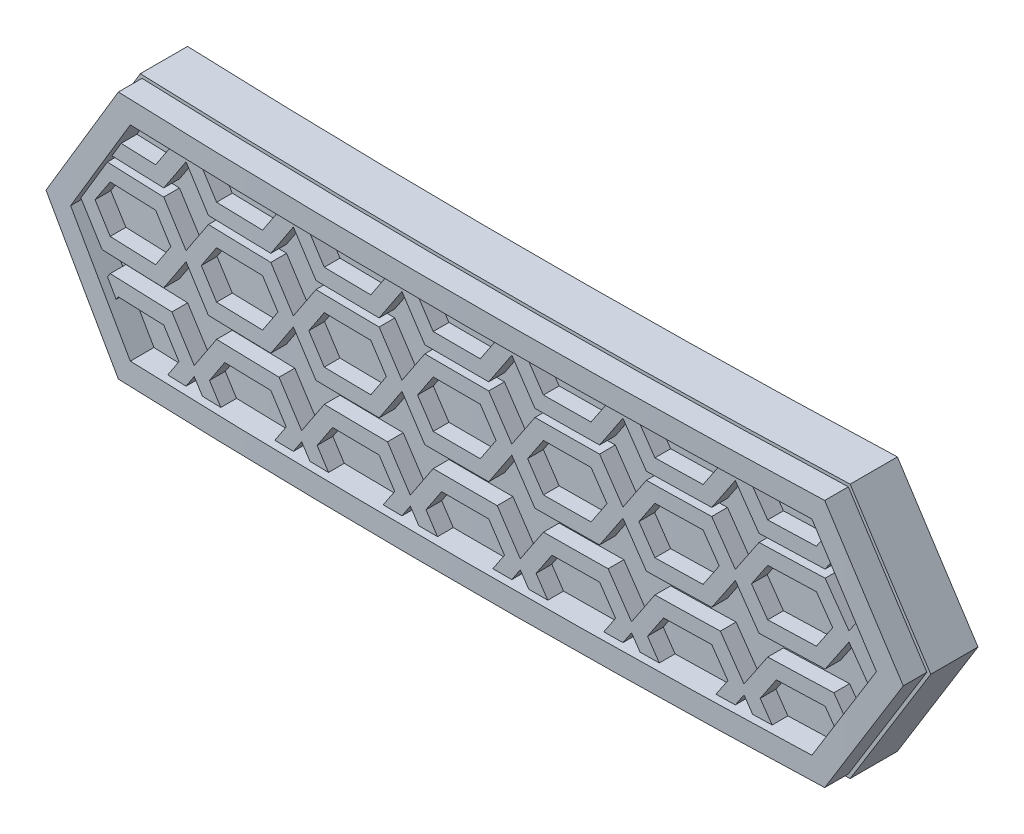
from build123d import *

# Parameters (mm, degrees)
BOSS_EXTRUDE1_DEPTH     = 25
SKETCH3_W               = 147
SKETCH3_H               = 25
CUT_EXTRUDE1_DEPTH      = 79.200997936
CUT_EXTRUDE1_DEPTH_BACK = 79.200997936
BOSS_EXTRUDE2_DEPTH     = 10
CUT_EXTRUDE2_DEPTH      = 34.52758126
BOSS_EXTRUDE3_DEPTH     = 10
CUT_EXTRUDE3_DEPTH      = 20


with BuildPart() as part:
    # Sketch2 → Boss-Extrude1 (new body)
    with BuildSketch(Plane(origin=(0, 0, 0), x_dir=(1, 0, 0), z_dir=(0, 1, 0))):
        with BuildLine():
            Line((-73.115286629, 2.629690485), (-72.75191537, 5.607602728))
            ThreePointArc((-72.75191537, 5.607602728), (0.384713371, 1.161945481), (73.521342111, 5.607602728))
            Line((73.521342111, 5.607602728), (73.884713371, 2.629690485))
            ThreePointArc((73.884713371, 2.629690485), (0.384713371, -1.838054519), (-73.115286629, 2.629690485))
        make_face()
    extrude(amount=BOSS_EXTRUDE1_DEPTH)

    # Sketch3 → Cut-Extrude1 (cut, two sides)
    with BuildSketch(Plane.XY) as cut_extrude1_sk:
        with Locations((0.384713371, 12.5)):
            Rectangle(SKETCH3_W, SKETCH3_H)
        Polygon((-27.593722221, 12.739217796), (-22.67085544, 20.843000849), (22.483410998, 20.843000849), (27.406277779, 12.739217796), (22.483410998, 4.635434742), (-22.67085544, 4.635434742), align=None, mode=Mode.SUBTRACT)
    extrude(amount=CUT_EXTRUDE1_DEPTH, mode=Mode.SUBTRACT)
    extrude(cut_extrude1_sk.sketch, amount=-CUT_EXTRUDE1_DEPTH_BACK, mode=Mode.SUBTRACT)

    # Sketch4 → Boss-Extrude2 (add)
    with BuildSketch(Plane.XY):
        Polygon((-25.625034682, 13.090843621), (-24.158033307, 10.890341559), (-20.08766579, 10.890341559), (-18.622849549, 13.087565921), (-17.158033307, 10.890341559), (-13.08766579, 10.890341559), (-11.622849549, 13.087565921), (-10.158033307, 10.890341559), (-6.08766579, 10.890341559), (-4.622849549, 13.087565921), (-3.158033307, 10.890341559), (0.91233421, 10.890341559), (2.377150451, 13.087565921), (3.841966693, 10.890341559), (7.91233421, 10.890341559), (9.377150451, 13.087565921), (10.841966693, 10.890341559), (14.91233421, 10.890341559), (16.377150451, 13.087565921), (17.841966693, 10.890341559), (21.91233421, 10.890341559), (23.377150451, 13.087565921), (24.67771394, 11.136720688), (25.250723794, 12.079981545), (24.377150451, 13.390341559), (24.836806139, 14.07982509), (24.263796285, 15.023085947), (23.377150451, 13.693117197), (21.91233421, 15.890341559), (17.841966693, 15.890341559), (16.377150451, 13.693117197), (14.91233421, 15.890341559), (10.841966693, 15.890341559), (9.377150451, 13.693117197), (7.91233421, 15.890341559), (3.841966693, 15.890341559), (2.377150451, 13.693117197), (0.91233421, 15.890341559), (-3.158033307, 15.890341559), (-4.622849549, 13.693117197), (-6.08766579, 15.890341559), (-10.158033307, 15.890341559), (-11.622849549, 13.693117197), (-13.08766579, 15.890341559), (-17.158033307, 15.890341559), (-18.622849549, 13.693117197), (-20.08766579, 15.890341559), (-23.924402359, 15.890341559), align=None)
        Polygon((-23.622849549, 14.890341559), (-20.622849549, 14.890341559), (-19.622849549, 13.390341559), (-20.622849549, 11.890341559), (-23.622849549, 11.890341559), (-24.622849549, 13.390341559), align=None, mode=Mode.SUBTRACT)
        Polygon((-16.622849549, 14.890341559), (-13.622849549, 14.890341559), (-12.622849549, 13.390341559), (-13.622849549, 11.890341559), (-16.622849549, 11.890341559), (-17.622849549, 13.390341559), align=None, mode=Mode.SUBTRACT)
        Polygon((-9.622849549, 14.890341559), (-6.622849549, 14.890341559), (-5.622849549, 13.390341559), (-6.622849549, 11.890341559), (-9.622849549, 11.890341559), (-10.622849549, 13.390341559), align=None, mode=Mode.SUBTRACT)
        Polygon((-2.622849549, 14.890341559), (0.377150451, 14.890341559), (1.377150451, 13.390341559), (0.377150451, 11.890341559), (-2.622849549, 11.890341559), (-3.622849549, 13.390341559), align=None, mode=Mode.SUBTRACT)
        Polygon((4.377150451, 14.890341559), (7.377150451, 14.890341559), (8.377150451, 13.390341559), (7.377150451, 11.890341559), (4.377150451, 11.890341559), (3.377150451, 13.390341559), align=None, mode=Mode.SUBTRACT)
        Polygon((11.377150451, 14.890341559), (14.377150451, 14.890341559), (15.377150451, 13.390341559), (14.377150451, 11.890341559), (11.377150451, 11.890341559), (10.377150451, 13.390341559), align=None, mode=Mode.SUBTRACT)
        Polygon((18.377150451, 14.890341559), (21.377150451, 14.890341559), (22.377150451, 13.390341559), (21.377150451, 11.890341559), (18.377150451, 11.890341559), (17.377150451, 13.390341559), align=None, mode=Mode.SUBTRACT)
        Polygon((-23.01318594, 17.390341559), (-23.620663552, 16.390341559), (-20.08766579, 16.390341559), (-18.622849549, 18.587565921), (-17.158033307, 16.390341559), (-13.08766579, 16.390341559), (-11.622849549, 18.587565921), (-10.158033307, 16.390341559), (-6.08766579, 16.390341559), (-4.622849549, 18.587565921), (-3.158033307, 16.390341559), (0.912334212, 16.390341557), (2.377150452, 18.587565921), (3.841966695, 16.39034156), (7.912334212, 16.39034156), (9.377150452, 18.587565924), (10.841966695, 16.390341563), (14.912334212, 16.390341563), (16.377150452, 18.587565927), (17.841966695, 16.390341566), (21.91233421, 16.390341559), (22.708102227, 17.583993585), (22.135092374, 18.527254443), (21.377150451, 17.390341559), (18.377150451, 17.390341559), (17.377150451, 18.890341559), (17.678923311, 19.343000849), (16.477072886, 19.343000849), (16.377150451, 19.193117197), (16.277228016, 19.343000849), (15.075377591, 19.343000849), (15.377150451, 18.890341559), (14.377150451, 17.390341559), (11.377150451, 17.390341559), (10.377150451, 18.890341559), (10.678923311, 19.343000849), (9.477072886, 19.343000849), (9.377150451, 19.193117197), (9.277228016, 19.343000849), (8.075377591, 19.343000849), (8.377150451, 18.890341559), (7.377150451, 17.390341559), (4.377150451, 17.390341559), (3.377150451, 18.890341559), (3.678923311, 19.343000849), (2.477072886, 19.343000849), (2.377150451, 19.193117197), (2.277228016, 19.343000849), (1.075377591, 19.343000849), (1.377150451, 18.890341559), (0.377150451, 17.390341559), (-2.622849549, 17.390341559), (-3.622849549, 18.890341559), (-3.321076689, 19.343000849), (-4.522927114, 19.343000849), (-4.622849549, 19.193117197), (-4.722771984, 19.343000849), (-5.924622409, 19.343000849), (-5.622849549, 18.890341559), (-6.622849549, 17.390341559), (-9.622849549, 17.390341559), (-10.622849549, 18.890341559), (-10.321076689, 19.343000849), (-11.522927114, 19.343000849), (-11.622849549, 19.193117197), (-11.722771984, 19.343000849), (-12.924622409, 19.343000849), (-12.622849549, 18.890341559), (-13.622849549, 17.390341559), (-16.622849549, 17.390341559), (-17.622849549, 18.890341559), (-17.321076689, 19.343000849), (-18.522927114, 19.343000849), (-18.622849549, 19.193117197), (-18.722771984, 19.343000849), (-19.924622409, 19.343000849), (-19.622849549, 18.890341559), (-20.622849549, 17.390341559), align=None)
        Polygon((2.577370532, 18.887896043), (2.577370532, 18.892787075), (2.579000876, 18.890341559), align=None, mode=Mode.SUBTRACT)
        Polygon((-23.621013766, 9.844421416), (-23.861228184, 9.484099789), (-23.28821833, 8.540838931), (-23.085830007, 8.844421416), (-20.085830007, 8.844421416), (-19.085830007, 7.344421416), (-19.891821123, 6.135434742), (-18.689970698, 6.135434742), (-18.085830007, 7.041645778), (-17.481689317, 6.135434742), (-16.279838892, 6.135434742), (-17.085830007, 7.344421416), (-16.085830007, 8.844421416), (-13.085830007, 8.844421416), (-12.085830007, 7.344421416), (-12.891821123, 6.135434742), (-11.689970698, 6.135434742), (-11.085830007, 7.041645778), (-10.481689317, 6.135434742), (-9.279838892, 6.135434742), (-10.085830007, 7.344421416), (-9.085830007, 8.844421416), (-6.085830007, 8.844421416), (-5.085830007, 7.344421416), (-5.891821123, 6.135434742), (-4.689970698, 6.135434742), (-4.085830007, 7.041645778), (-3.481689317, 6.135434742), (-2.279838892, 6.135434742), (-3.085830007, 7.344421416), (-2.085830007, 8.844421416), (0.914169993, 8.844421416), (1.914169993, 7.344421416), (1.108178877, 6.135434742), (2.310029302, 6.135434742), (2.914169993, 7.041645778), (3.518310683, 6.135434742), (4.720161108, 6.135434742), (3.914169993, 7.344421416), (4.914169993, 8.844421416), (7.914169993, 8.844421416), (8.914169993, 7.344421416), (8.108178877, 6.135434742), (9.310029302, 6.135434742), (9.914169993, 7.041645778), (10.518310683, 6.135434742), (11.720161108, 6.135434742), (10.914169993, 7.344421416), (11.914169993, 8.844421416), (14.914169993, 8.844421416), (15.914169993, 7.344421416), (15.108178877, 6.135434742), (16.310029302, 6.135434742), (16.914169993, 7.041645778), (17.518310683, 6.135434742), (18.720161108, 6.135434742), (17.914169993, 7.344421416), (18.914169993, 8.844421416), (21.914169993, 8.844421416), (22.63152646, 7.768386715), (23.204536314, 8.711647573), (22.449353734, 9.844421474), (18.378986217, 9.844421473), (16.914169993, 7.6471971), (15.449353734, 9.84442145), (11.378986217, 9.84442145), (9.914169993, 7.647197077), (8.449353734, 9.844421427), (4.378986217, 9.844421427), (2.914169993, 7.647197053), (1.449353752, 9.844421416), (-2.621013766, 9.844421416), (-4.085830007, 7.647197053), (-5.550646249, 9.844421416), (-9.621013766, 9.844421416), (-11.085830007, 7.647197053), (-12.550646249, 9.844421416), (-16.621013766, 9.844421416), (-18.085830007, 7.647197053), (-19.550646249, 9.844421416), align=None)
        Polygon((3.114390074, 7.341975899), (3.114390074, 7.346866932), (3.116020418, 7.344421416), align=None, mode=Mode.SUBTRACT)
    extrude(amount=BOSS_EXTRUDE2_DEPTH)

    # Sketch5 → Cut-Extrude2 (cut, through all)
    with BuildSketch(Plane(origin=(0, 20.843000849, 0), x_dir=(1, 0, 0), z_dir=(0, 1, 0))):
        with BuildLine():
            Line((-27.639829066, -2.191649177), (-28.043350207, -10.934212227))
            Line((-28.043350207, -10.934212227), (27.450807756, -11.687353018))
            Line((27.450807756, -11.687353018), (27.450807756, -2.235129205))
            ThreePointArc((27.450807756, -2.235129205), (24.985520784, -2.340003798), (22.519828375, -2.434869384))
            ThreePointArc((22.519828375, -2.434869384), (-0.094842688, -2.837865338), (-22.708849685, -2.399184828))
            ThreePointArc((-22.708849685, -2.399184828), (-25.174550019, -2.300421833), (-27.639829066, -2.191649177))
        make_face()
    extrude(amount=-CUT_EXTRUDE2_DEPTH, mode=Mode.SUBTRACT)

    # Sketch6 → Boss-Extrude3 (add)
    with BuildSketch(Plane.XY):
        Polygon((27.172266749, 12.739217796), (22.370895491, 20.643000849), (-22.558339933, 20.643000849), (-27.359711191, 12.739217796), (-22.558339933, 4.835434742), (22.370895491, 4.835434742), align=None)
        Polygon((-21.770731383, 19.243000849), (-25.721633984, 12.739217796), (-21.770731383, 6.235434742), (21.583286941, 6.235434742), (25.534189542, 12.739217796), (21.583286941, 19.243000849), align=None, mode=Mode.SUBTRACT)
    extrude(amount=BOSS_EXTRUDE3_DEPTH)

    # Sketch7 → Cut-Extrude3 (cut)
    with BuildSketch(Plane(origin=(0, 20.843000849, 0), x_dir=(1, 0, 0), z_dir=(0, 1, 0))):
        with BuildLine():
            Line((-27.662882489, -2.691117434), (-27.662882489, -11.541885058))
            Line((-27.662882489, -11.541885058), (28.347762014, -11.541885058))
            Line((28.347762014, -11.541885058), (27.473072744, -2.734633229))
            ThreePointArc((27.473072744, -2.734633229), (25.005757789, -2.839594094), (22.538037063, -2.934537717))
            ThreePointArc((22.538037063, -2.934537717), (-0.095237179, -3.337865183), (-22.727846808, -2.898823807))
            ThreePointArc((-22.727846808, -2.898823807), (-25.195575465, -2.799979568), (-27.662882489, -2.691117434))
        make_face()
    extrude(amount=-CUT_EXTRUDE3_DEPTH, mode=Mode.SUBTRACT)


solid = part.part
